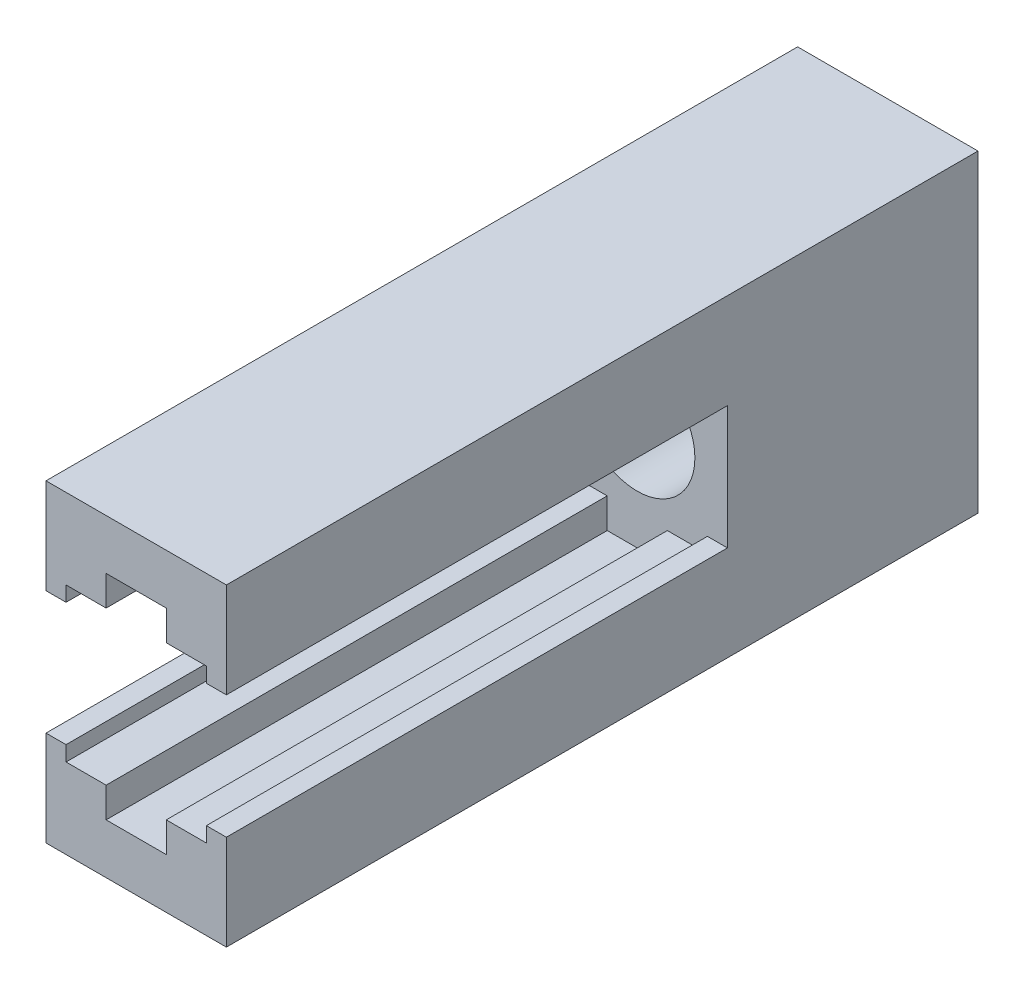
from build123d import *

# Parameters (mm, degrees)
BOSS_EXTRUDE1_DEPTH = 50
SKETCH3_W           = 18
SKETCH3_H           = 31.3
BOSS_EXTRUDE2_DEPTH = 25
SKETCH4_R           = 5.75
CUT_EXTRUDE1_DEPTH  = 16
SKETCH5_R           = 3.5
CUT_EXTRUDE2_DEPTH  = 10


with BuildPart() as part:
    # Sketch2 → Boss-Extrude1 (new body)
    with BuildSketch(Plane.XY):
        Polygon((-3, -10.65), (3, -10.65), (3, -7.65), (7, -7.65), (7, -6.15), (9, -6.15), (9, -7.65), (9, -15.65), (-9, -15.65), (-9, -7.65), (-9, -6.15), (-7, -6.15), (-7, -7.65), (-3, -7.65), align=None)
    extrude(amount=BOSS_EXTRUDE1_DEPTH)


with BuildPart() as body_2:
    # Mirror2: mirrored copy
    add(part.part.mirror(Plane.ZX))


with BuildPart() as part_1:
    add(part.part)

    add(body_2.part)  # Boss-Extrude2 merges body 2
    # Sketch3 → Boss-Extrude2 (add)
    with BuildSketch(Plane(origin=(0, 0, 0), x_dir=(-1, 0, 0), z_dir=(0, 0, -1))):
        Rectangle(SKETCH3_W, SKETCH3_H)
    extrude(amount=BOSS_EXTRUDE2_DEPTH)

    # Sketch4 → Cut-Extrude1 (cut)
    with BuildSketch(Plane.XY):
        Circle(SKETCH4_R)
    extrude(amount=-CUT_EXTRUDE1_DEPTH, mode=Mode.SUBTRACT)

    # Sketch5 → Cut-Extrude2 (cut, through all)
    with BuildSketch(Plane.XY.offset(-16)):
        Circle(SKETCH5_R)
    extrude(amount=-CUT_EXTRUDE2_DEPTH, mode=Mode.SUBTRACT)


solid = part_1.part
